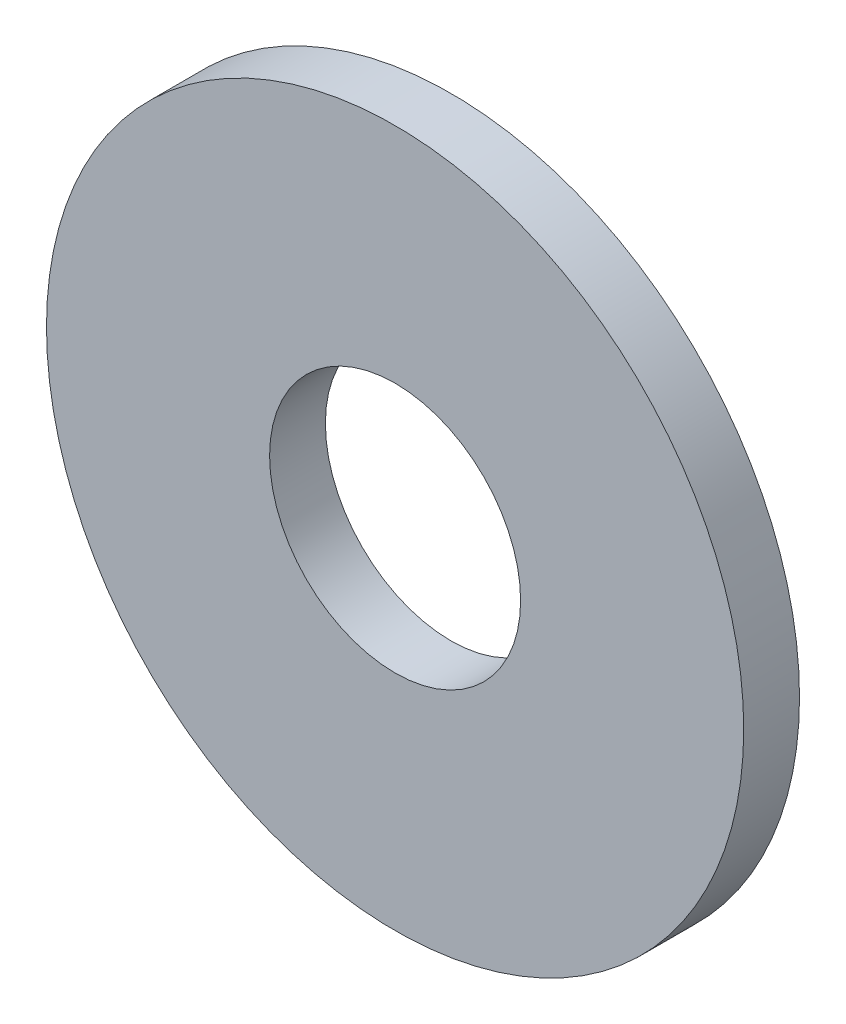
from build123d import *

# Parameters (mm, degrees)
SKETCH1_R           = 5
SKETCH1_R_2         = 1.8
BOSS_EXTRUDE1_DEPTH = 0.8


with BuildPart() as part:
    # Sketch1 → Boss-Extrude1 (new body)
    with BuildSketch(Plane.XY):
        Circle(SKETCH1_R)
        Circle(SKETCH1_R_2, mode=Mode.SUBTRACT)
    extrude(amount=BOSS_EXTRUDE1_DEPTH)


solid = part.part
